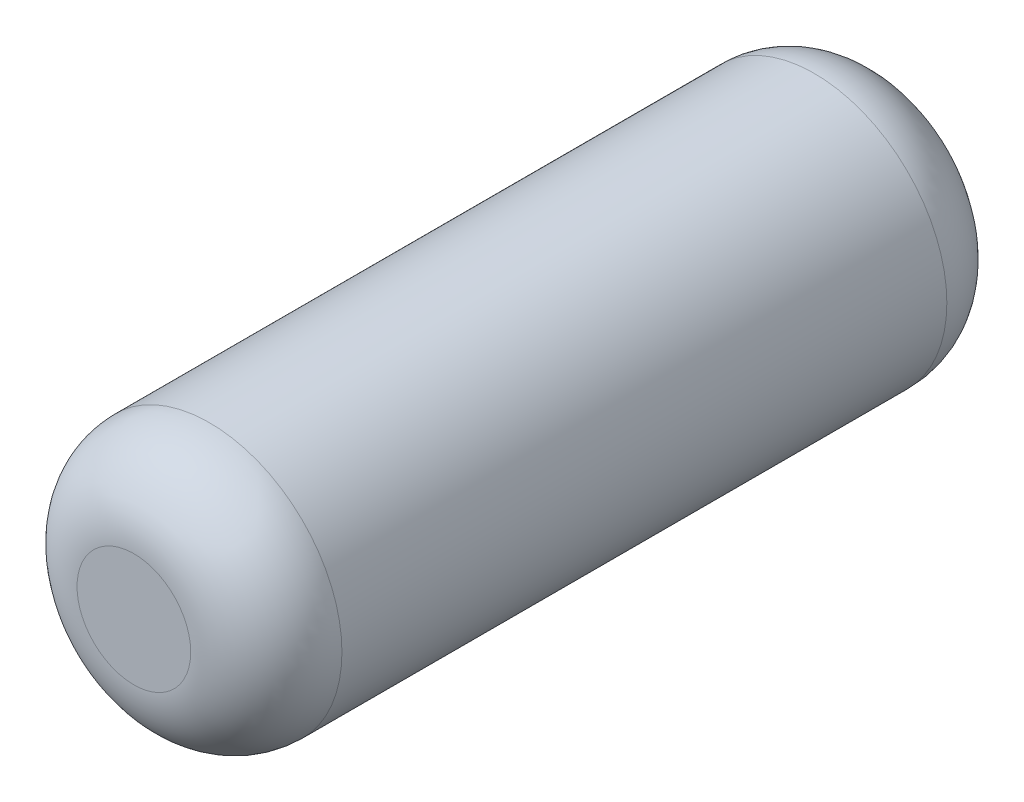
from build123d import *

# Parameters (mm, degrees)
SKETCH1_R      = 44.49044586
EXTRUDE1_DEPTH = 254
FILLET1_R      = 25.4


with BuildPart() as part:
    # Sketch1 → Extrude1 (new body)
    with BuildSketch(Plane.XY):
        Circle(SKETCH1_R)
    extrude(amount=EXTRUDE1_DEPTH)

    # Fillet1
    fillet1_edges = [part.edges().sort_by_distance(p)[0] for p in [
        (-44.49044586, 0, 0),
        (-44.49044586, 0, 254),
    ]]
    fillet(fillet1_edges, radius=FILLET1_R)


solid = part.part
